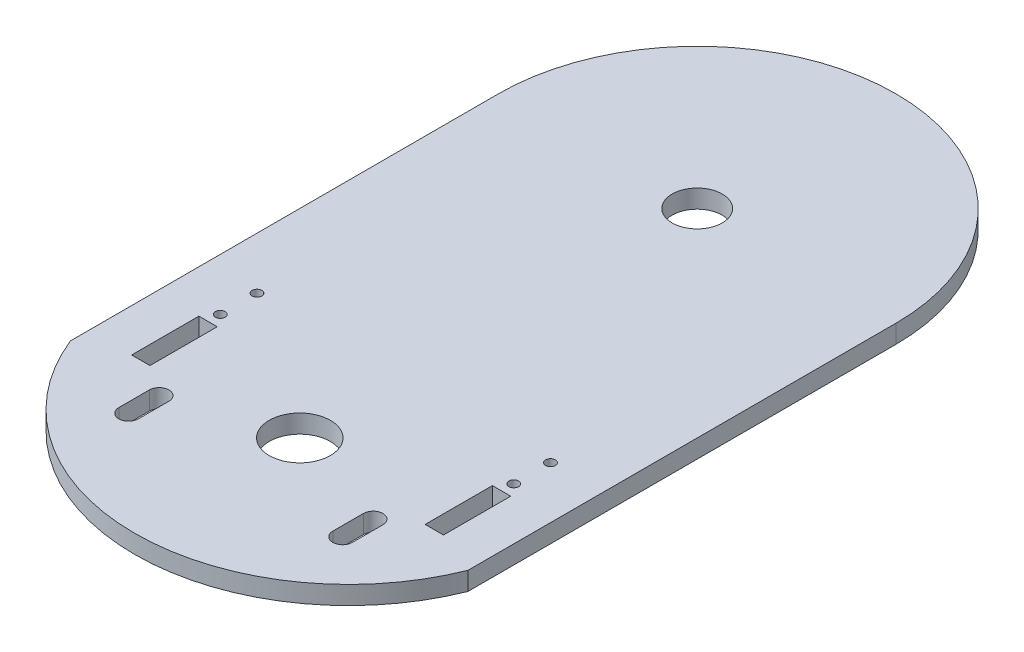
from build123d import *

# Parameters (mm, degrees)
BOSS_EXTRUDE1_DEPTH = 3
SKETCH2_R           = 4.1
SKETCH2_R_2         = 5
SKETCH2_R_3         = 1.6
CUT_EXTRUDE1_DEPTH  = 4
SKETCH3_R           = 0.8
SKETCH3_W           = 3
SKETCH3_H           = 11
CUT_EXTRUDE2_DEPTH  = 4
CUT_EXTRUDE3_DEPTH  = 4


with BuildPart() as part:
    # Sketch1 → Boss-Extrude1 (new body)
    with BuildSketch(Plane(origin=(0, 0, 0), x_dir=(1, 0, 0), z_dir=(0, 1, 0))):
        with BuildLine():
            Line((-32.5, -35), (-32.5, 35))
            ThreePointArc((-32.5, 35), (0, 67.5), (32.5, 35))
            Line((32.5, 35), (32.5, -35))
            ThreePointArc((32.5, -35), (0, -57.009618943), (-32.5, -35))
        make_face()
    extrude(amount=BOSS_EXTRUDE1_DEPTH)

    # Sketch2 → Cut-Extrude1 (cut, through all)
    with BuildSketch(Plane(origin=(0, 3, 0), x_dir=(1, 0, 0), z_dir=(0, 1, 0))):
        with Locations((0, 35)):
            Circle(SKETCH2_R)
        with Locations((0, -30)):
            Circle(SKETCH2_R_2)
        with Locations((-17.5, -38)):
            Circle(SKETCH2_R_3)
        with Locations((17.5, -38)):
            Circle(SKETCH2_R_3)
    extrude(amount=-CUT_EXTRUDE1_DEPTH, mode=Mode.SUBTRACT)

    # Sketch3 → Cut-Extrude2 (cut, through all)
    with BuildSketch(Plane(origin=(0, 3, 0), x_dir=(1, 0, 0), z_dir=(0, 1, 0))):
        with Locations((-24, -13)):
            Circle(SKETCH3_R)
        with Locations((-24, -19)):
            Circle(SKETCH3_R)
        with Locations((24, -19)):
            Circle(SKETCH3_R)
        with Locations((24, -13)):
            Circle(SKETCH3_R)
        with Locations((24, -26.5)):
            Rectangle(SKETCH3_W, SKETCH3_H)
        with Locations((-24, -26.5)):
            Rectangle(SKETCH3_W, SKETCH3_H)
    extrude(amount=-CUT_EXTRUDE2_DEPTH, mode=Mode.SUBTRACT)

    # Sketch4 → Cut-Extrude3 (cut, through all)
    with BuildSketch(Plane(origin=(0, 3, 0), x_dir=(1, 0, 0), z_dir=(0, 1, 0))):
        with BuildLine():
            Line((-15.9, -35.5), (-15.9, -40.5))
            ThreePointArc((-15.9, -40.5), (-17.5, -42.1), (-19.1, -40.5))
            Line((-19.1, -40.5), (-19.1, -35.5))
            ThreePointArc((-19.1, -35.5), (-17.5, -33.9), (-15.9, -35.5))
        make_face()
        with BuildLine():
            Line((15.9, -35.5), (15.9, -40.5))
            ThreePointArc((15.9, -40.5), (17.5, -42.1), (19.1, -40.5))
            Line((19.1, -40.5), (19.1, -35.5))
            ThreePointArc((19.1, -35.5), (17.5, -33.9), (15.9, -35.5))
        make_face()
    extrude(amount=-CUT_EXTRUDE3_DEPTH, mode=Mode.SUBTRACT)


solid = part.part
